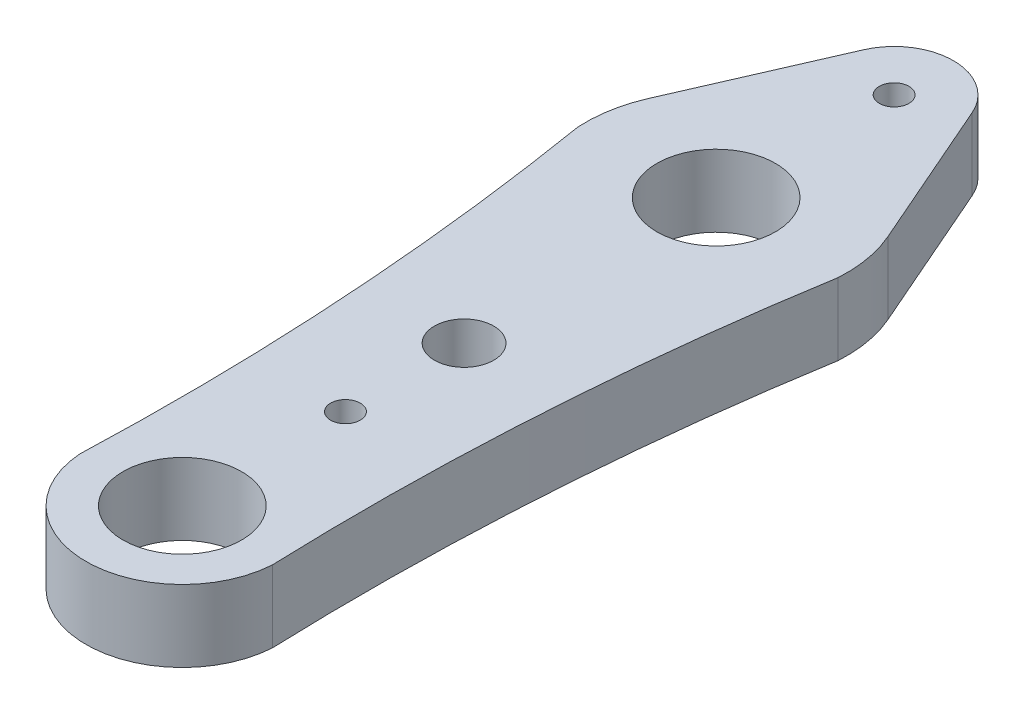
from build123d import *

# Parameters (mm, degrees)
SKETCH1_R           = 4
SKETCH1_R_2         = 1
SKETCH1_R_3         = 2
BOSS_EXTRUDE1_DEPTH = 4.85


with BuildPart() as part:
    # Sketch1 → Boss-Extrude1 (new body)
    with BuildSketch(Plane(origin=(0, 0, 0), x_dir=(1, 0, 0), z_dir=(0, 1, 0))):
        with BuildLine():
            Line((-3.666060556, 30.6), (-8.065333223, 20.52))
            ThreePointArc((-8.065333223, 20.52), (-8.667437744, 18.521684251), (-8.782021759, 16.437777778))
            ThreePointArc((-8.782021759, 16.437777778), (-8.64730319, 15.61122755), (-8.516431626, 14.784059485))
            ThreePointArc((-8.516431626, 14.784059485), (-6.724262557, -1.642204863), (-6.445963017, -18.163602496))
            ThreePointArc((-6.445963017, -18.163602496), (-6.465253257, -18.789475583), (-6.486720617, -19.415277778))
            ThreePointArc((-6.486720617, -19.415277778), (0, -25.5), (6.486720617, -19.415277778))
            ThreePointArc((6.486720617, -19.415277778), (6.465253257, -18.789475583), (6.445963017, -18.163602496))
            ThreePointArc((6.445963017, -18.163602496), (6.724262557, -1.642204863), (8.516431626, 14.784059485))
            ThreePointArc((8.516431626, 14.784059485), (8.64730319, 15.61122755), (8.782021759, 16.437777778))
            ThreePointArc((8.782021759, 16.437777778), (8.667437744, 18.521684251), (8.065333223, 20.52))
            Line((8.065333223, 20.52), (3.666060556, 30.6))
            ThreePointArc((3.666060556, 30.6), (0, 33), (-3.666060556, 30.6))
        make_face()
        with Locations((0, -19)):
            Circle(SKETCH1_R, mode=Mode.SUBTRACT)
        with Locations((0, -8)):
            Circle(SKETCH1_R_2, mode=Mode.SUBTRACT)
        Circle(SKETCH1_R_3, mode=Mode.SUBTRACT)
        with Locations((0, 17)):
            Circle(SKETCH1_R, mode=Mode.SUBTRACT)
        with Locations((0, 29)):
            Circle(SKETCH1_R_2, mode=Mode.SUBTRACT)
    extrude(amount=BOSS_EXTRUDE1_DEPTH)


solid = part.part
